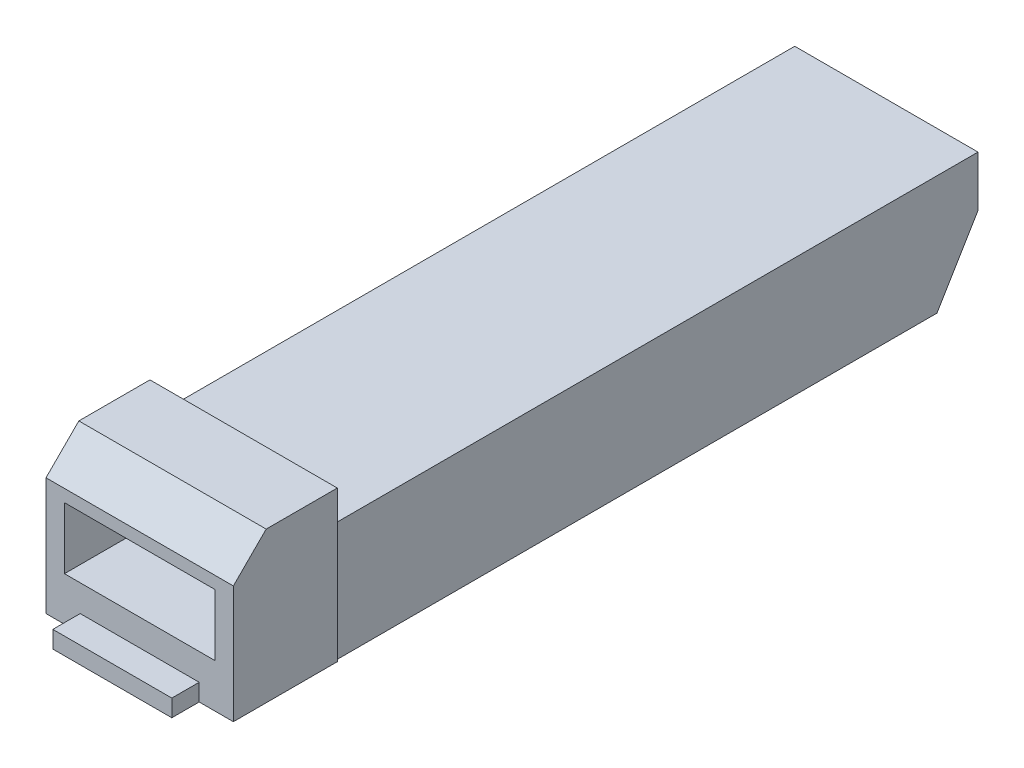
from build123d import *

# Parameters (mm, degrees)
SKETCH1_W           = 13.4
SKETCH1_H           = 47
BOSS_EXTRUDE1_DEPTH = 8.7
CUT_EXTRUDE1_DEPTH  = 35.015262457
SKETCH3_W           = 13.7
SKETCH3_H           = 11
BOSS_EXTRUDE2_DEPTH = 7.6
CUT_EXTRUDE2_DEPTH  = 42.529397245
SKETCH5_W           = 8.7
SKETCH5_H           = 1.25
BOSS_EXTRUDE3_DEPTH = 2
SKETCH7_W           = 11
SKETCH7_H           = 4.5
CUT_EXTRUDE3_DEPTH  = 9.5


with BuildPart() as part:
    # Sketch1 → Boss-Extrude1 (new body)
    with BuildSketch(Plane(origin=(0, 0, 0), x_dir=(1, 0, 0), z_dir=(0, 1, 0))):
        with Locations((0, -6.529786546)):
            Rectangle(SKETCH1_W, SKETCH1_H)
    extrude(amount=BOSS_EXTRUDE1_DEPTH)

    # Sketch2 → Cut-Extrude1 (cut, through all)
    with BuildSketch(Plane.ZY.offset(6.7)):
        Polygon((-16.970213454, 0), (-16.970213454, 5), (-13.970213454, 0), align=None)
    extrude(amount=-CUT_EXTRUDE1_DEPTH, mode=Mode.SUBTRACT)

    # Sketch3 → Boss-Extrude2 (add)
    with BuildSketch(Plane.XY.offset(30.029786546)):
        with Locations((0, 5.5)):
            Rectangle(SKETCH3_W, SKETCH3_H)
    extrude(amount=BOSS_EXTRUDE2_DEPTH)

    # Sketch4 → Cut-Extrude2 (cut, through all)
    with BuildSketch(Plane.ZY.offset(6.85)):
        Polygon((37.629786546, 11), (35.229786546, 11), (37.629786546, 8.6), align=None)
    extrude(amount=-CUT_EXTRUDE2_DEPTH, mode=Mode.SUBTRACT)

    # Sketch7 → Cut-Extrude3 (cut)
    with BuildSketch(Plane.XY.offset(37.629786546)):
        with Locations((0, 5.45)):
            Rectangle(SKETCH7_W, SKETCH7_H)
    extrude(amount=-CUT_EXTRUDE3_DEPTH, mode=Mode.SUBTRACT)


with BuildPart() as body_2:
    # Sketch5 → Boss-Extrude3 (new body)
    with BuildSketch(Plane.XY.offset(37.629786546)):
        with Locations((0, 0.625)):
            Rectangle(SKETCH5_W, SKETCH5_H)
    extrude(amount=BOSS_EXTRUDE3_DEPTH)


solid = Compound([part.part, body_2.part])
